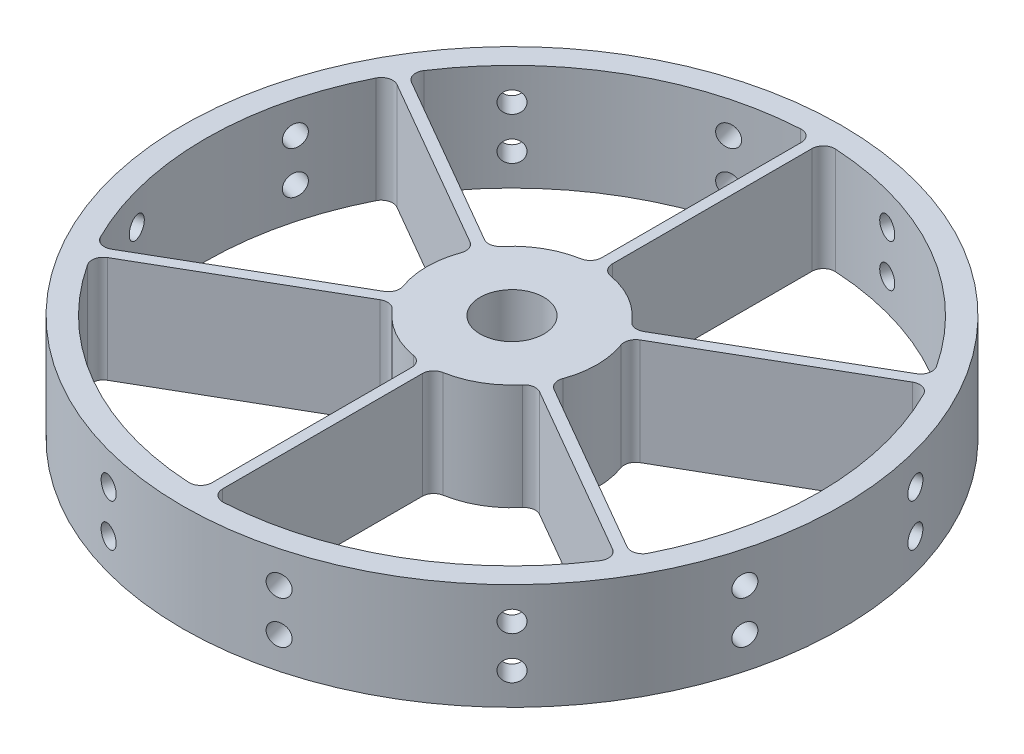
from build123d import *

# Parameters (mm, degrees)
RING_R                = 25.4
BOSS_EXTRUDE1_DEPTH   = 15.875
RING_R_2              = 98.425
RING_R_3              = 91.567
BOSS_EXTRUDE1_2_DEPTH = 15.875
BOSS_EXTRUDE2_DEPTH   = 15.875
CIRPATTERN1_COUNT     = 6
FILLET1_R             = 3.429
SKETCH8_R             = 9.525
CUT_EXTRUDE1_DEPTH    = 143.76912744
CUT_EXTRUDE2_START    = 38.1
SKETCH10_R            = 3.175
CUT_EXTRUDE2_DEPTH    = 102.996312853
CIRPATTERN3_COUNT     = 12


with BuildPart() as part:
    # ring → Boss-Extrude1 (new, symmetric)
    with BuildSketch(Plane(origin=(0, 0, 0), x_dir=(1, 0, 0), z_dir=(0, 1, 0))):
        Circle(RING_R)
    extrude(amount=BOSS_EXTRUDE1_DEPTH, both=True)



with BuildPart() as body_2:
    # ring → Boss-Extrude1 2 (new, symmetric)
    with BuildSketch(Plane(origin=(0, 0, 0), x_dir=(1, 0, 0), z_dir=(0, 1, 0))):
        Circle(RING_R_2)
        Circle(RING_R_3, mode=Mode.SUBTRACT)
    extrude(amount=BOSS_EXTRUDE1_2_DEPTH, both=True)


with BuildPart() as part_1:
    add(part.part)

    add(body_2.part)  # Boss-Extrude2 merges body 2
    # beam → Boss-Extrude2 (add, symmetric)
    with BuildSketch(Plane(origin=(0, 0, 0), x_dir=(1, 0, 0), z_dir=(0, 1, 0))):
        with BuildLine():
            Line((1.5875, 25.350342083), (1.5875, 97.777113599))
            ThreePointArc((1.5875, 97.777113599), (0, 97.79), (-1.5875, 97.777113599))
            Line((-1.5875, 97.777113599), (-1.5875, 25.350342083))
            ThreePointArc((-1.5875, 25.350342083), (0, 25.4), (1.5875, 25.350342083))
        make_face()
    boss_extrude2 = extrude(amount=BOSS_EXTRUDE2_DEPTH, both=True)

    # CirPattern1: Boss-Extrude2 ×6 about axis
    cirpattern1_axis = Axis((0, 21.835457169, 0), (0, -1, 0))
    for i in range(1, CIRPATTERN1_COUNT):
        add(boss_extrude2.rotate(cirpattern1_axis, i * 360 / CIRPATTERN1_COUNT))

    # Fillet1
    fillet1_edges = [part_1.edges().sort_by_distance(p)[0] for p in [
        (-80.081179644, 0, 44.40180352),
        (-80.081179644, 0, -44.40180352),
        (-22.747790239, 0, 11.300355713),
        (-22.747790239, 0, -11.300355713),
        (-21.160290239, 0, -14.04998637),
        (-1.5875, 0, -25.350342083),
        (-78.493679644, 0, -47.151434177),
        (-1.5875, 0, -91.553237697),
        (1.5875, 0, -91.553237697),
        (78.493679644, 0, -47.151434177),
        (21.160290239, 0, -14.04998637),
        (1.5875, 0, -25.350342083),
        (22.747790239, 0, 11.300355713),
        (22.747790239, 0, -11.300355713),
        (80.081179644, 0, 44.40180352),
        (80.081179644, 0, -44.40180352),
        (1.5875, 0, 91.553237697),
        (1.5875, 0, 25.350342083),
        (21.160290239, 0, 14.04998637),
        (78.493679644, 0, 47.151434177),
        (-1.5875, 0, 91.553237697),
        (-1.5875, 0, 25.350342083),
        (-21.160290239, 0, 14.04998637),
        (-78.493679644, 0, 47.151434177),
    ]]
    fillet(fillet1_edges, radius=FILLET1_R)

    # Sketch8 → Cut-Extrude1 (cut, through all)
    with BuildSketch(Plane(origin=(0, 15.875, 0), x_dir=(1, 0, 0), z_dir=(0, 1, 0))):
        Circle(SKETCH8_R)
    extrude(amount=-CUT_EXTRUDE1_DEPTH, mode=Mode.SUBTRACT)

    # Sketch10 → Cut-Extrude2 (cut, through all)
    with BuildSketch(Plane(origin=(0, 0, 0), x_dir=(0, -1, 0), z_dir=(-0.25881904510251796, 0, -0.9659258262890691)).offset(CUT_EXTRUDE2_START)):
        with Locations((-6.35, 0)):
            Circle(SKETCH10_R)
        with Locations((6.35, 0)):
            Circle(SKETCH10_R)
    cut_extrude2 = extrude(amount=CUT_EXTRUDE2_DEPTH, mode=Mode.SUBTRACT)

    # CirPattern3: Cut-Extrude2 ×12 about axis
    cirpattern3_axis = Axis((0, 15.875, 0), (0, -1, 0))
    for i in range(1, CIRPATTERN3_COUNT):
        add(cut_extrude2.rotate(cirpattern3_axis, i * 360 / CIRPATTERN3_COUNT), mode=Mode.SUBTRACT)


solid = part_1.part
